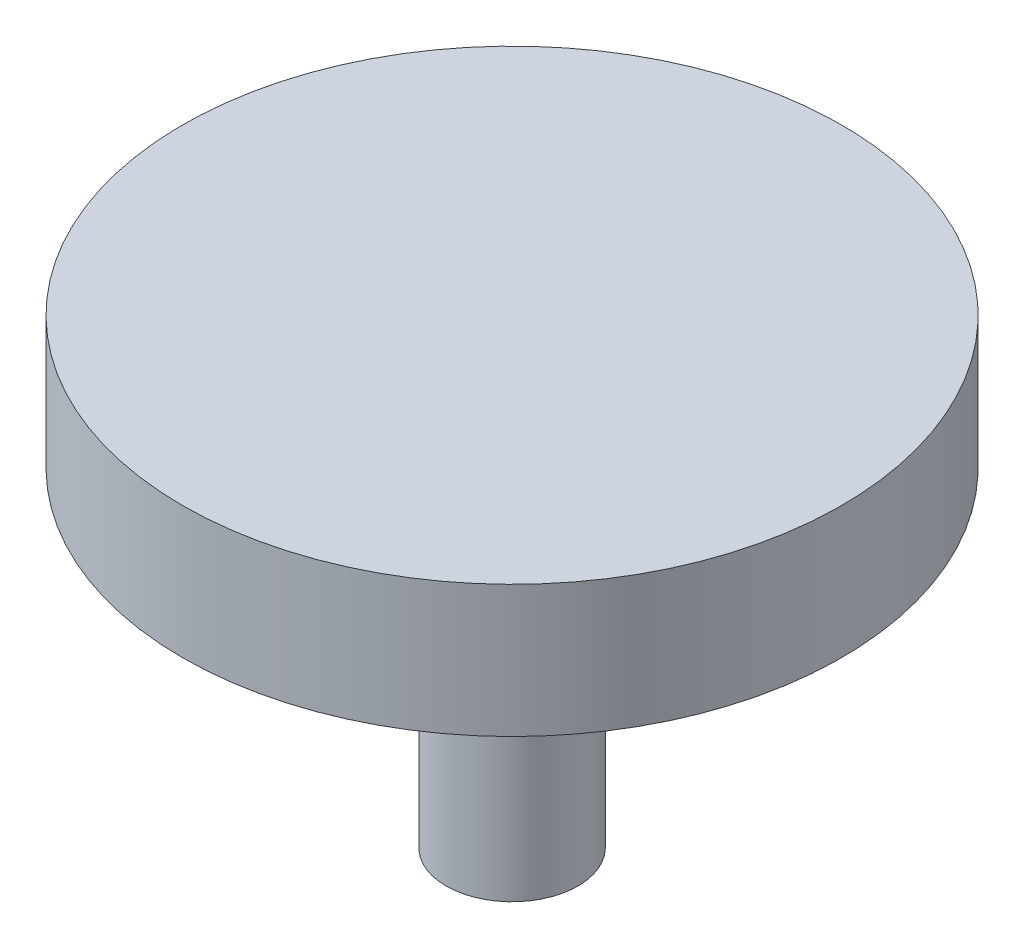
from build123d import *

# Parameters (mm, degrees)
SKETCH1_R           = 25
BOSS_EXTRUDE1_DEPTH = 10
SKETCH2_R           = 5
BOSS_EXTRUDE2_DEPTH = 25


with BuildPart() as part:
    # Sketch1 → Boss-Extrude1 (new body)
    with BuildSketch(Plane(origin=(0, 0, 0), x_dir=(1, 0, 0), z_dir=(0, 1, 0))):
        Circle(SKETCH1_R)
    extrude(amount=BOSS_EXTRUDE1_DEPTH)

    # Sketch2 → Boss-Extrude2 (add)
    with BuildSketch(Plane(origin=(0, 0, 0), x_dir=(1, 0, 0), z_dir=(0, 1, 0))):
        Circle(SKETCH2_R)
    extrude(amount=-BOSS_EXTRUDE2_DEPTH)


solid = part.part
